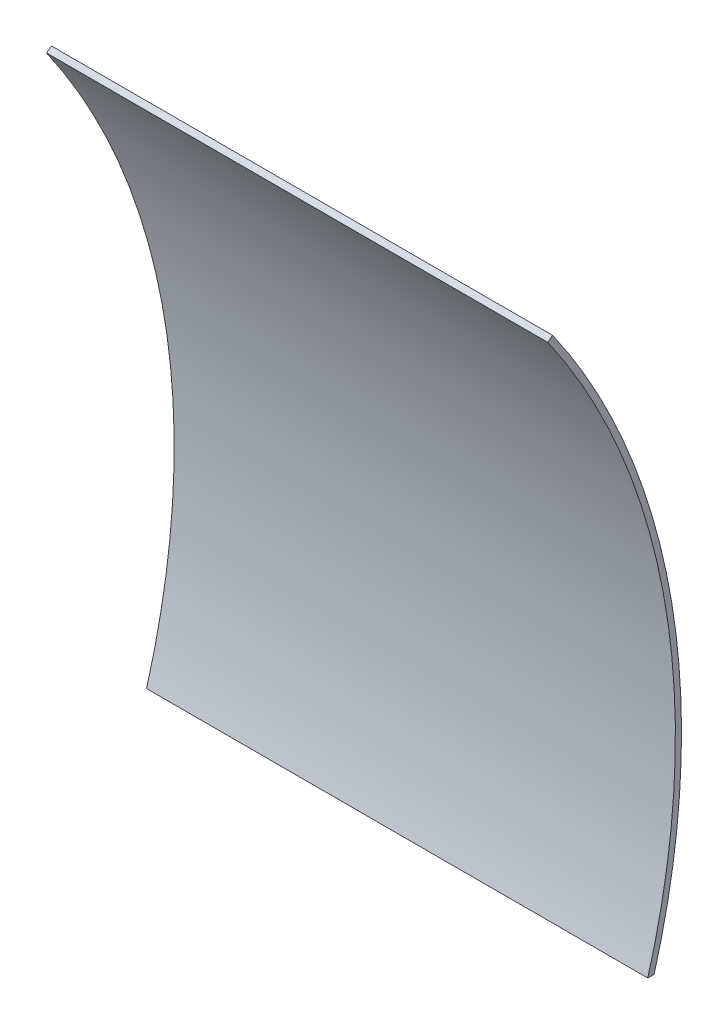
from build123d import *

# Parameters (mm, degrees)
BOSS_EXTRUDE1_DEPTH = 130.175


with BuildPart() as part:
    # Sketch1 → Boss-Extrude1 (new body)
    with BuildSketch(Plane(origin=(0, 0, 0), x_dir=(0, 0, -1), z_dir=(1, 0, 0))):
        with BuildLine():
            Line((176.178529946, -50.8), (177.830117427, -50.8))
            ThreePointArc((177.830117427, -50.8), (182.392106967, 30.615518615), (151.497050891, 106.07937705))
            Line((151.497050891, 106.07937705), (150.196647021, 105.168824458))
            ThreePointArc((150.196647021, 105.168824458), (174.869963651, 55.13628775), (183.35625, 0))
            ThreePointArc((183.35625, 0), (181.552952325, -25.652288715), (176.178529946, -50.8))
        make_face()
    extrude(amount=BOSS_EXTRUDE1_DEPTH)


solid = part.part
